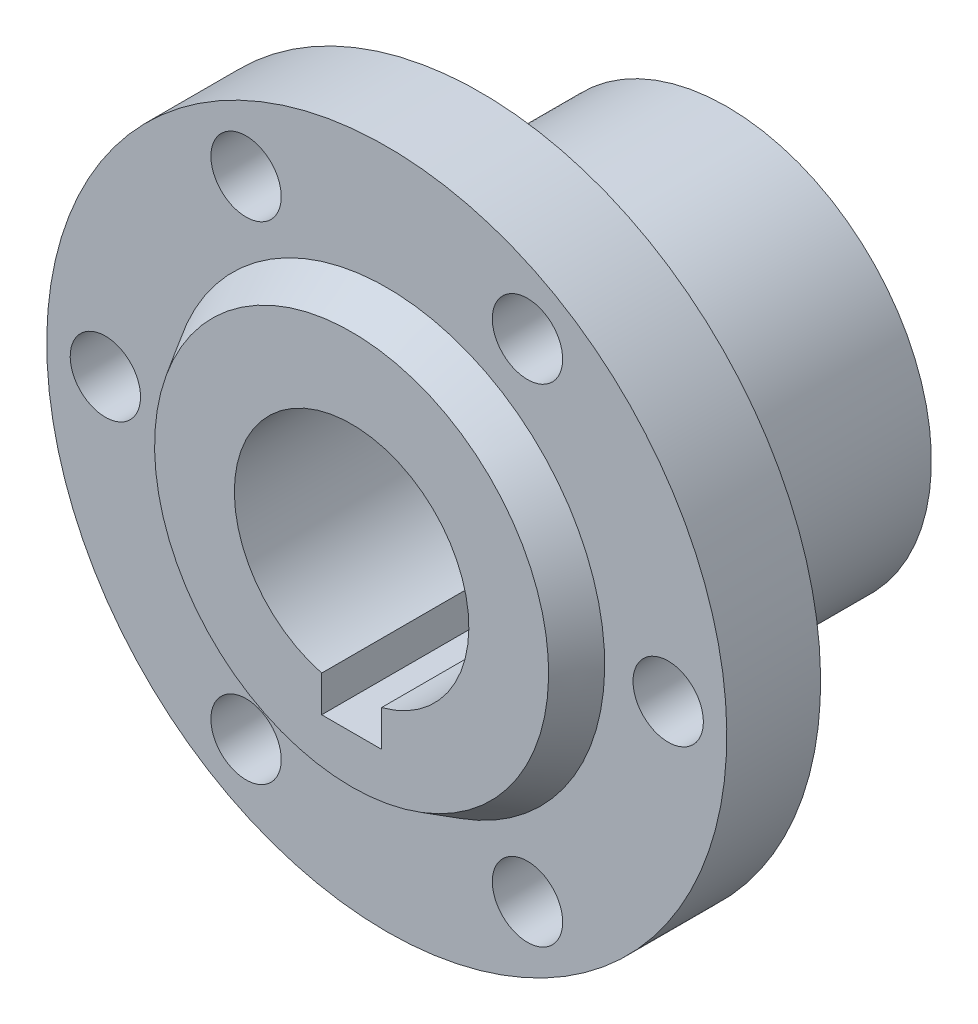
from build123d import *

# Parameters (mm, degrees)
CUT_EXTRUDE1_DEPTH      = 12
CUT_EXTRUDE1_DEPTH_BACK = 22
SKETCH3_R               = 3
CUT_EXTRUDE2_DEPTH      = 22
CUT_EXTRUDE2_DEPTH_BACK = 12


with BuildPart() as part:
    # Sketch1 → Revolve1 (revolve)
    with BuildSketch(Plane(origin=(0, 0, 0), x_dir=(0, 0, -1), z_dir=(1, 0, 0))):
        Polygon((21, 17.45), (7.03, 17.45), (7.03, 18.5), (0, 18.5), (0, 29), (-8, 29), (-8, 18.586235054), (-11, 16.803216346), (-11, 10), (21, 10), align=None)
    revolve(axis=Axis((0, 0, 11), (0, 0, -1)))

    # Sketch2 → Cut-Extrude1 (cut, two sides)
    with BuildSketch(Plane.XY) as cut_extrude1_sk:
        with BuildLine():
            Line((-2.55, -12.75), (2.55, -12.75))
            Line((2.55, -12.75), (2.55, -9.66941053))
            ThreePointArc((2.55, -9.66941053), (0, -10), (-2.55, -9.66941053))
            Line((-2.55, -9.66941053), (-2.55, -12.75))
        make_face()
    extrude(amount=CUT_EXTRUDE1_DEPTH, mode=Mode.SUBTRACT)
    extrude(cut_extrude1_sk.sketch, amount=-CUT_EXTRUDE1_DEPTH_BACK, mode=Mode.SUBTRACT)

    # Sketch3 → Cut-Extrude2 (cut, two sides)
    with BuildSketch(Plane(origin=(0, 0, 0), x_dir=(-1, 0, 0), z_dir=(0, 0, -1))) as cut_extrude2_sk:
        with Locations((-24, 0)):
            Circle(SKETCH3_R)
        with Locations((-12, 20.784609691)):
            Circle(SKETCH3_R)
        with Locations((12, 20.784609691)):
            Circle(SKETCH3_R)
        with Locations((24, 0)):
            Circle(SKETCH3_R)
        with Locations((12, -20.784609691)):
            Circle(SKETCH3_R)
        with Locations((-12, -20.784609691)):
            Circle(SKETCH3_R)
    extrude(amount=CUT_EXTRUDE2_DEPTH, mode=Mode.SUBTRACT)
    extrude(cut_extrude2_sk.sketch, amount=-CUT_EXTRUDE2_DEPTH_BACK, mode=Mode.SUBTRACT)


solid = part.part
